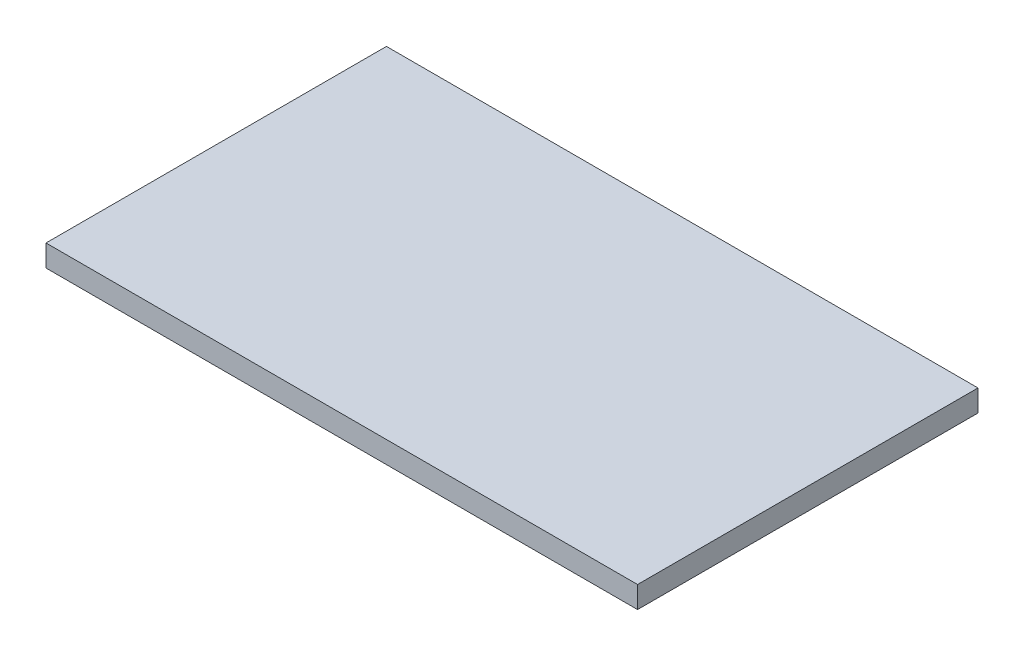
from build123d import *

# Parameters (mm, degrees)
SKETCH_1_W      = 490
SKETCH_1_H      = 282
EXTRUDE_1_DEPTH = 18


with BuildPart() as part:
    # Эскиз1 → Бобышка-Вытянуть1 (new body)
    with BuildSketch(Plane(origin=(0, 0, 0), x_dir=(1, 0, 0), z_dir=(0, 1, 0))):
        Rectangle(SKETCH_1_W, SKETCH_1_H)
    extrude(amount=EXTRUDE_1_DEPTH)


solid = part.part
